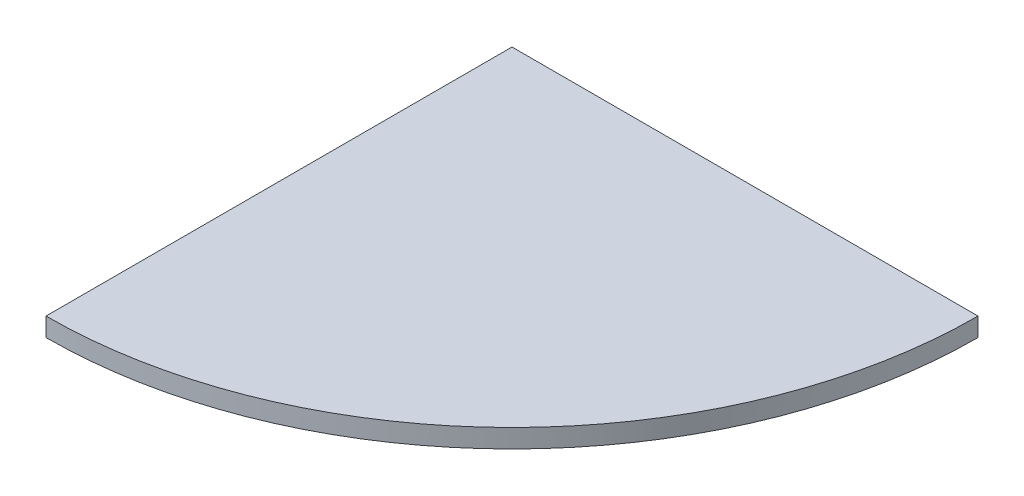
from build123d import *

# Parameters (mm, degrees)
BOSS_EXTRUDE1_DEPTH = 18


with BuildPart() as part:
    # Sketch1 → Boss-Extrude1 (new body)
    with BuildSketch(Plane(origin=(0, 0, 0), x_dir=(1, 0, 0), z_dir=(0, 1, 0))):
        with BuildLine():
            Line((0, 0), (450, 0))
            ThreePointArc((450, 0), (318.198051534, -318.198051534), (0, -450))
            Line((0, -450), (0, 0))
        make_face()
    extrude(amount=BOSS_EXTRUDE1_DEPTH)


solid = part.part
